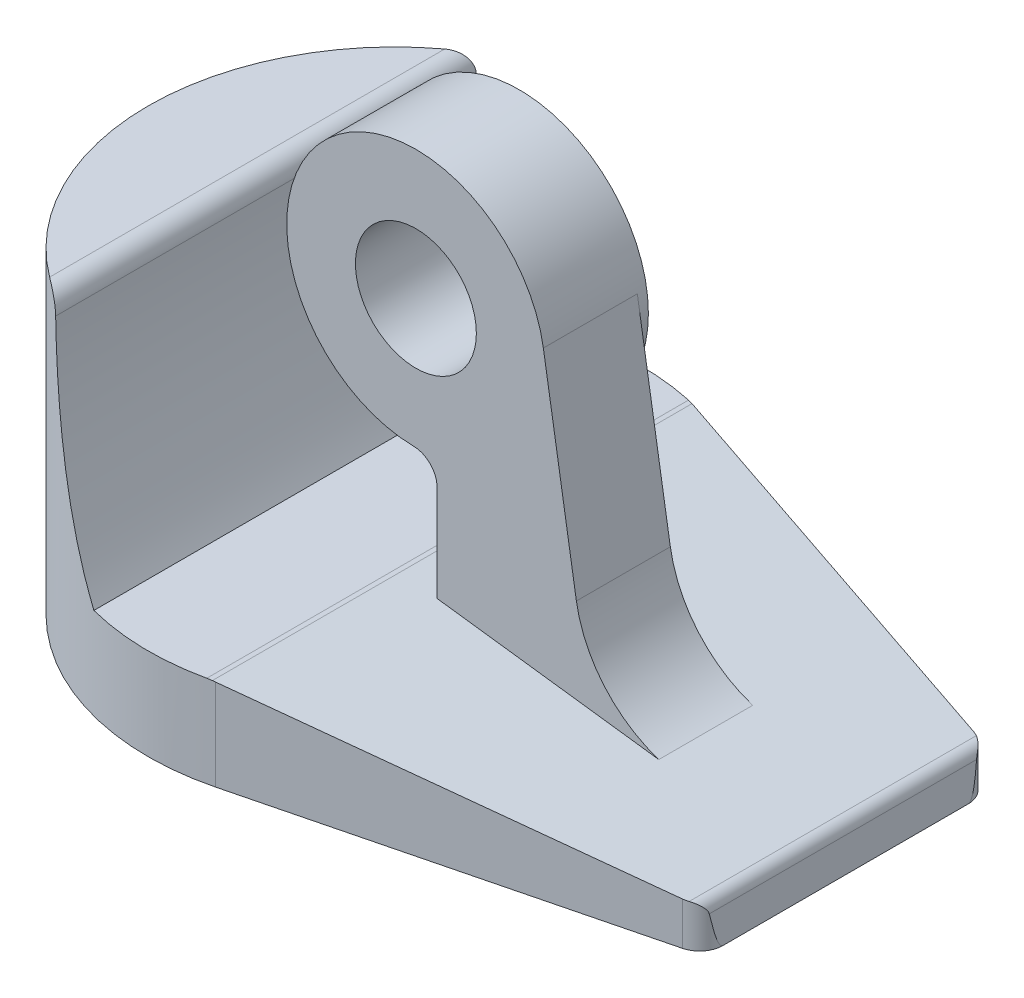
from build123d import *

# Parameters (mm, degrees)
SKETCH1_R                = 10.5
BOSS_EXTRUDE1_DEPTH      = 13.5
CUT_EXTRUDE1_DEPTH       = 11.5
CUT_EXTRUDE1_DEPTH_BACK  = 11.5
SKETCH5_R                = 5.5
SKETCH5_R_2              = 2.575
BOSS_EXTRUDE2_DEPTH      = 2.2
BOSS_EXTRUDE2_DEPTH_BACK = 1.8
SKETCH5_4_R              = 5.5
SKETCH5_4_R_2            = 2.575
BOSS_EXTRUDE3_DEPTH      = 2.2
FILLET1_R                = 1


with BuildPart() as part:
    # Sketch1 → Boss-Extrude1 (new body)
    with BuildSketch(Plane(origin=(0, 0, 0), x_dir=(1, 0, 0), z_dir=(0, 1, 0))):
        with BuildLine():
            Line((18.443804907, 6.19010049), (2.559951525, 10.18315512))
            ThreePointArc((2.559951525, 10.18315512), (8.280383174, 6.45641189), (10.5, 0))
            ThreePointArc((10.5, 0), (8.280383174, -6.45641189), (2.559951525, -10.18315512))
            Line((2.559951525, -10.18315512), (18.443804907, -6.19010049))
            ThreePointArc((18.443804907, -6.19010049), (18.988607921, -5.835172564), (19.2, -5.220276193))
            Line((19.2, -5.220276193), (19.2, 5.220276193))
            ThreePointArc((19.2, 5.220276193), (18.988607921, 5.835172564), (18.443804907, 6.19010049))
        make_face()
        Circle(SKETCH1_R)
    extrude(amount=BOSS_EXTRUDE1_DEPTH)

    # Sketch2 → Cut-Extrude1 (cut, two sides)
    with BuildSketch(Plane.XY) as cut_extrude1_sk:
        with BuildLine():
            Line((-85.748448257, 13.5), (-10.5, 13.5))
            Line((-10.5, 13.5), (-6.28259424, 13.5))
            ThreePointArc((-6.28259424, 13.5), (-5.729347477, 13.277856401), (-5.483351282, 12.73479505))
            ThreePointArc((-5.483351282, 12.73479505), (-4.659552595, 8.127259704), (-2.65, 3.9))
            Line((-2.65, 3.9), (2.253530088, 3.9))
            ThreePointArc((2.253530088, 3.9), (2.349801107, 3.896907442), (2.445675162, 3.887642521))
            Line((2.445675162, 3.887642521), (18.648491256, 1.794874091))
            ThreePointArc((18.648491256, 1.794874091), (18.945201048, 1.645191976), (19.082540247, 1.342571122))
            Line((19.082540247, 1.342571122), (19.2, 0))
            Line((19.2, 0), (25.758334398, -74.962105194))
            Line((25.758334398, -74.962105194), (119.29298444, 42.938637392))
            Line((119.29298444, 42.938637392), (7.786201784, 131.400742585))
            Line((7.786201784, 131.400742585), (-85.748448257, 13.5))
        make_face()
    extrude(amount=CUT_EXTRUDE1_DEPTH, mode=Mode.SUBTRACT)
    extrude(cut_extrude1_sk.sketch, amount=-CUT_EXTRUDE1_DEPTH_BACK, mode=Mode.SUBTRACT)

    # Sketch5 → Boss-Extrude2 (add, two sides)
    with BuildSketch(Plane.XY) as boss_extrude2_sk:
        with BuildLine():
            Line((9.93428712, 6.560044551), (8.528350834, 15.184876952))
            ThreePointArc((8.528350834, 15.184876952), (8.582058445, 14.743886479), (8.6, 14.3))
            ThreePointArc((8.6, 14.3), (7.295235393, 10.743316151), (4, 8.874136013))
            Line((4, 8.874136013), (4, 3.9))
            Line((4, 3.9), (4, 2.282191618))
            Line((4, 2.282191618), (14.2, 2.282191618))
            ThreePointArc((14.2, 2.282191618), (11.37916934, 3.735096256), (9.93428712, 6.560044551))
        make_face()
        with Locations((3.1, 14.3)):
            Circle(SKETCH5_R)
        with Locations((3.1, 14.3)):
            Circle(SKETCH5_R_2, mode=Mode.SUBTRACT)
    extrude(amount=BOSS_EXTRUDE2_DEPTH)
    extrude(boss_extrude2_sk.sketch, amount=-BOSS_EXTRUDE2_DEPTH_BACK)

    # Sketch5_4 → Boss-Extrude3 (add)
    with BuildSketch(Plane.XY):
        with Locations((3.1, 14.3)):
            Circle(SKETCH5_4_R)
        with Locations((3.1, 14.3)):
            Circle(SKETCH5_4_R_2, mode=Mode.SUBTRACT)
    extrude(amount=-BOSS_EXTRUDE3_DEPTH)

    # Fillet1
    fillet1_edges = [part.edges().sort_by_distance(p)[0] for p in [
        (4, 8.874136013, 0.2),
    ]]
    fillet(fillet1_edges, radius=FILLET1_R)


solid = part.part
